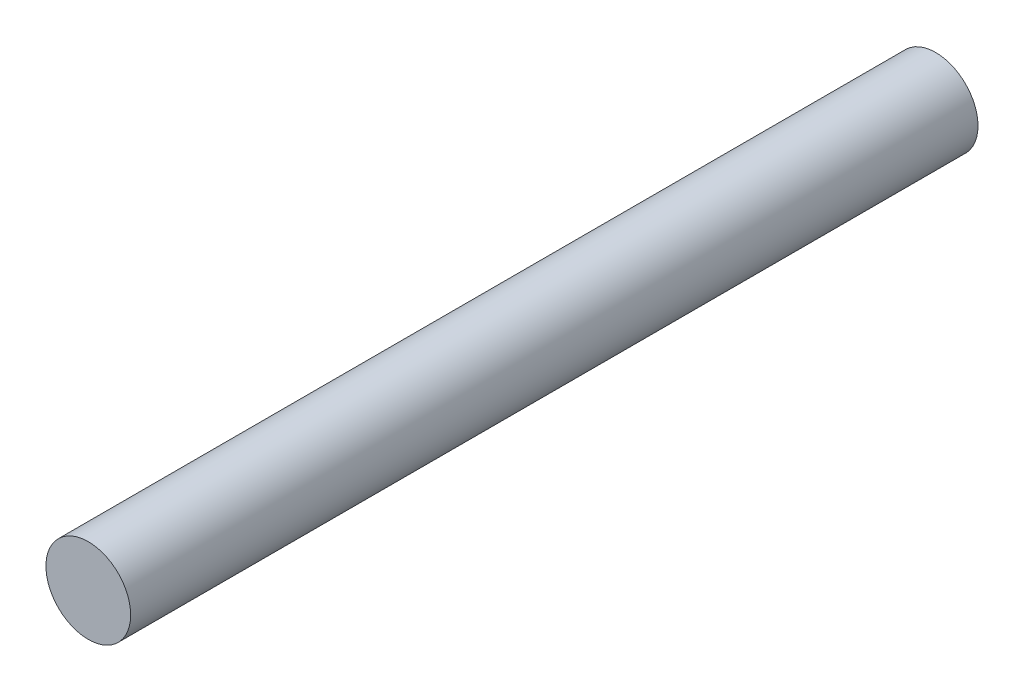
from build123d import *

# Parameters (mm, degrees)
SKETCH_1_R      = 4
EXTRUDE_1_DEPTH = 80


with BuildPart() as part:
    # 草图1 → 凸台-拉伸1 (new body)
    with BuildSketch(Plane.XY):
        Circle(SKETCH_1_R)
    extrude(amount=EXTRUDE_1_DEPTH)


solid = part.part
